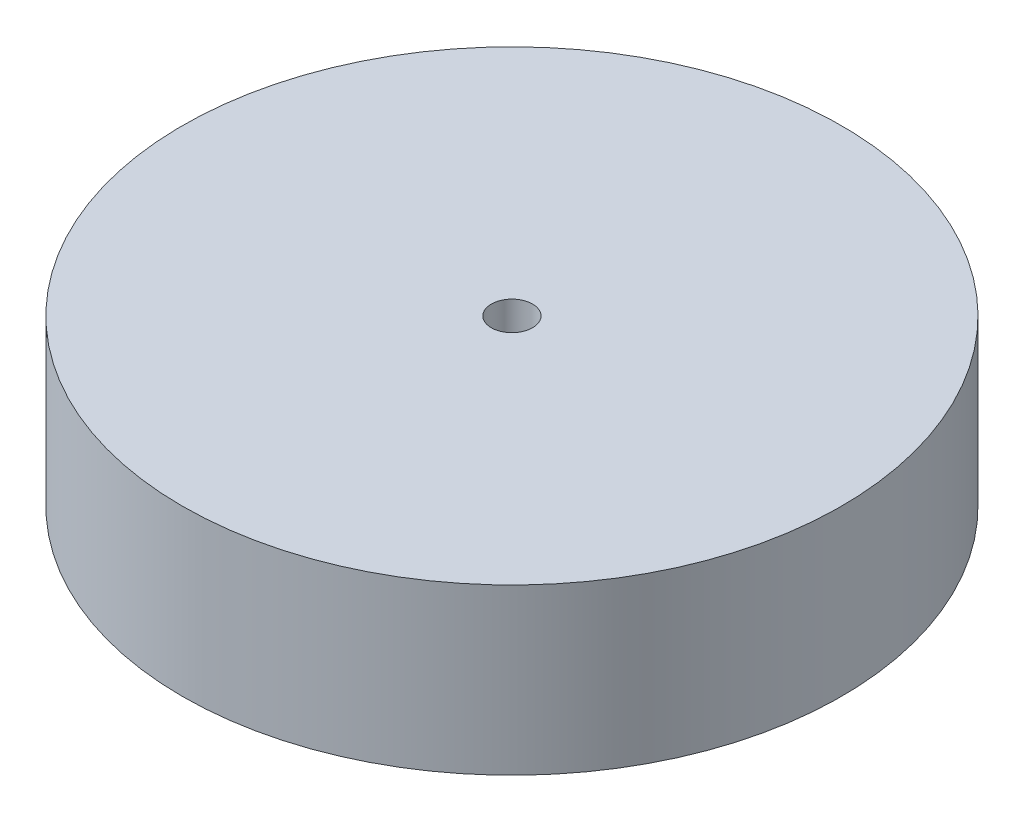
from build123d import *

# Parameters (mm, degrees)
SKETCH1_R           = 50.8
BOSS_EXTRUDE1_DEPTH = 25.4
SKETCH2_R           = 3.175
CUT_EXTRUDE1_DEPTH  = 25.4


with BuildPart() as part:
    # Sketch1 → Boss-Extrude1 (new body)
    with BuildSketch(Plane(origin=(0, 0, 0), x_dir=(1, 0, 0), z_dir=(0, 1, 0))):
        Circle(SKETCH1_R)
    extrude(amount=BOSS_EXTRUDE1_DEPTH)

    # Sketch2 → Cut-Extrude1 (cut)
    with BuildSketch(Plane(origin=(0, 25.4, 0), x_dir=(1, 0, 0), z_dir=(0, 1, 0))):
        Circle(SKETCH2_R)
    extrude(amount=-CUT_EXTRUDE1_DEPTH, mode=Mode.SUBTRACT)


solid = part.part
